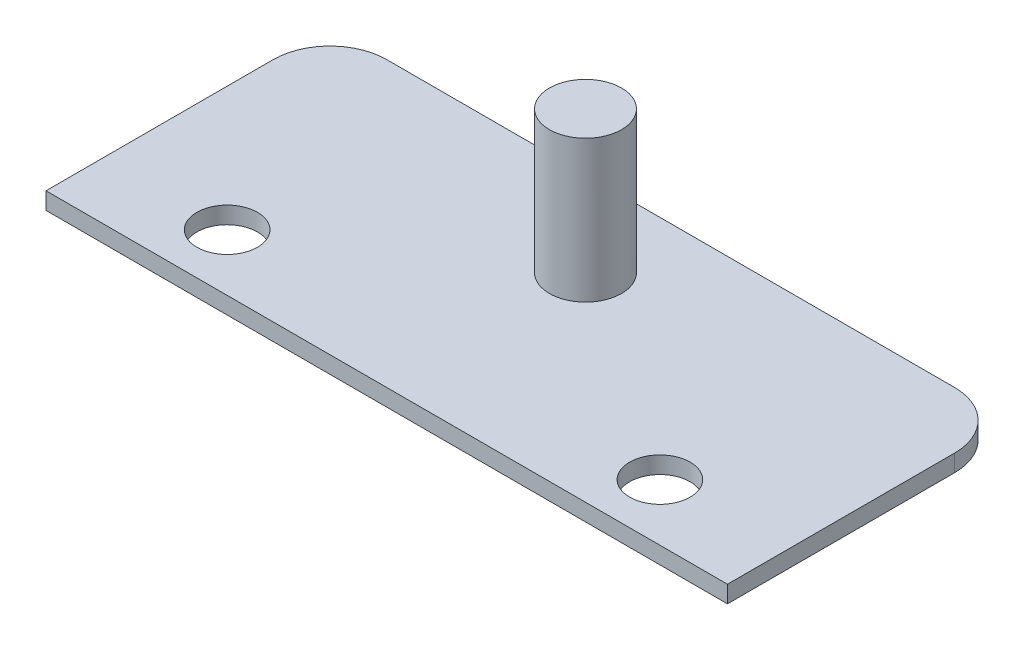
from build123d import *

# Parameters (mm, degrees)
SKETCH1_W           = 120
SKETCH1_H           = 50
BOSS_EXTRUDE1_DEPTH = 3
SKETCH2_R           = 5.334
CUT_EXTRUDE1_DEPTH  = 4
SKETCH3_R           = 6.35
BOSS_EXTRUDE2_DEPTH = 25
FILLET1_R           = 10


with BuildPart() as part:
    # Sketch1 → Boss-Extrude1 (new body)
    with BuildSketch(Plane(origin=(0, 0, 0), x_dir=(1, 0, 0), z_dir=(0, 1, 0))):
        with Locations((60, 25)):
            Rectangle(SKETCH1_W, SKETCH1_H)
    extrude(amount=BOSS_EXTRUDE1_DEPTH)

    # Sketch2 → Cut-Extrude1 (cut, through all)
    with BuildSketch(Plane(origin=(0, 3, 0), x_dir=(1, 0, 0), z_dir=(0, 1, 0))):
        with Locations((21.9, 10)):
            Circle(SKETCH2_R)
        with Locations((98.1, 10)):
            Circle(SKETCH2_R)
    extrude(amount=-CUT_EXTRUDE1_DEPTH, mode=Mode.SUBTRACT)

    # Sketch3 → Boss-Extrude2 (add)
    with BuildSketch(Plane(origin=(0, 3, 0), x_dir=(1, 0, 0), z_dir=(0, 1, 0))):
        with Locations((60, 35)):
            Circle(SKETCH3_R)
    extrude(amount=BOSS_EXTRUDE2_DEPTH)

    # Fillet1
    fillet1_edges = [part.edges().sort_by_distance(p)[0] for p in [
        (0, 1.5, -50),
        (120, 1.5, -50),
    ]]
    fillet(fillet1_edges, radius=FILLET1_R)


solid = part.part
